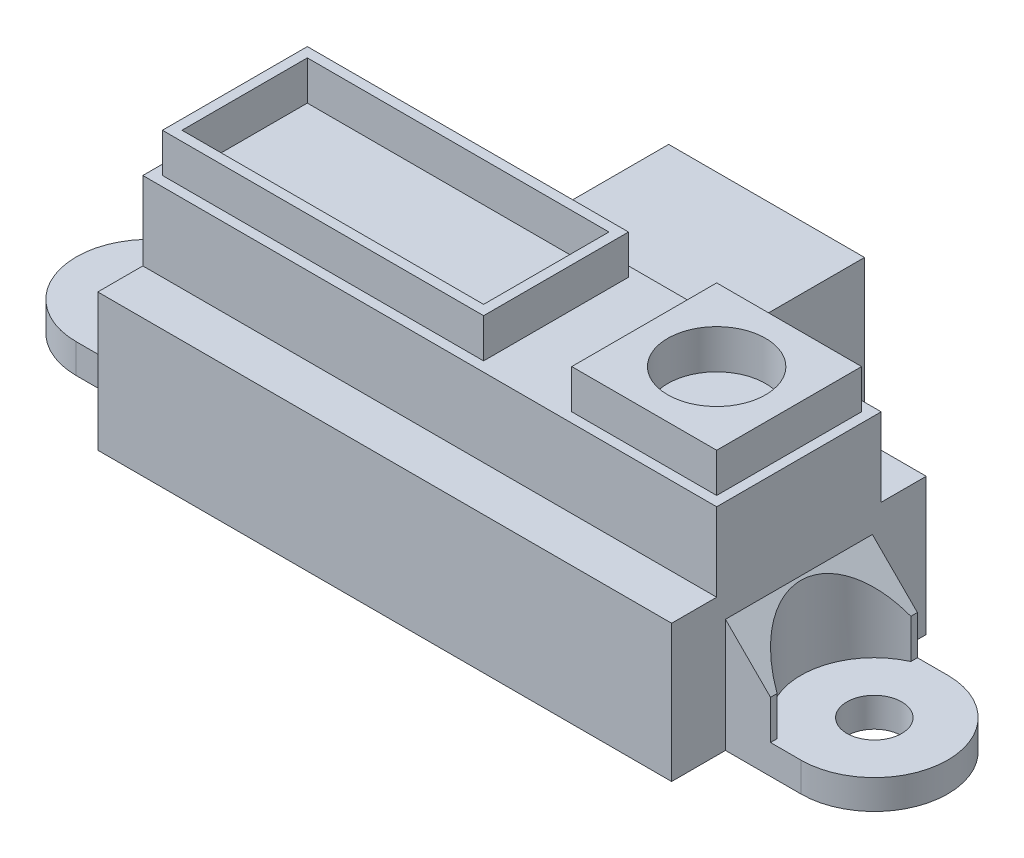
from build123d import *

# Parameters (mm, degrees)
SKETCH_1_W                  = 29.3
SKETCH_1_H                  = 13
EXTRUDE_1_DEPTH             = 7
SKETCH_2_W                  = 29.3
SKETCH_2_H                  = 8.4
EXTRUDE_2_DEPTH             = 4
SKETCH_3_W                  = 16.4
SKETCH_3_H                  = 7.4
SKETCH_3_W_2                = 15.4
SKETCH_3_H_2                = 6.4
SKETCH_3_W_3                = 7.4
SKETCH_3_R                  = 2.5
EXTRUDE_3_DEPTH             = 2
SKETCH_5_R                  = 1.4
EXTRUDE_4_DEPTH             = 5.8
CUT_EXTRUDE_1_DEPTH         = 5
SKETCH_7_R                  = 3.75
CUT_EXTRUDE_2_DEPTH         = 10
SKETCH_8_W                  = 10
SKETCH_8_H                  = 7
EXTRUDE_5_DEPTH             = 6.5
EXTRUDE_5_DIRECTION_2_REACH = 15


with BuildPart() as part:
    # 草图1 → 凸台-拉伸1 (new body)
    with BuildSketch(Plane(origin=(0, 0, 0), x_dir=(1, 0, 0), z_dir=(0, 1, 0))):
        Rectangle(SKETCH_1_W, SKETCH_1_H)
    extrude(amount=EXTRUDE_1_DEPTH)

    # 草图2 → 凸台-拉伸2 (add)
    with BuildSketch(Plane(origin=(0, 7, 0), x_dir=(1, 0, 0), z_dir=(0, 1, 0))):
        Rectangle(SKETCH_2_W, SKETCH_2_H)
    extrude(amount=EXTRUDE_2_DEPTH)

    # 草图3 → 凸台-拉伸3 (add)
    with BuildSketch(Plane(origin=(0, 11, 0), x_dir=(1, 0, 0), z_dir=(0, 1, 0))):
        with Locations((-5.95, 0)):
            Rectangle(SKETCH_3_W, SKETCH_3_H)
        with Locations((-5.95, 0)):
            Rectangle(SKETCH_3_W_2, SKETCH_3_H_2, mode=Mode.SUBTRACT)
        with Locations((10.45, 0)):
            Rectangle(SKETCH_3_W_3, SKETCH_3_H)
        with Locations((10.45, 0)):
            Circle(SKETCH_3_R, mode=Mode.SUBTRACT)
    extrude(amount=EXTRUDE_3_DEPTH)

    # 草图5 → 凸台-拉伸4 (add)
    with BuildSketch(Plane(origin=(0, 0, 0), x_dir=(1, 0, 0), z_dir=(0, 1, 0))):
        with BuildLine():
            Line((-18.5, 3.75), (18.5, 3.75))
            ThreePointArc((18.5, 3.75), (22.25, 0), (18.5, -3.75))
            Line((18.5, -3.75), (-18.5, -3.75))
            ThreePointArc((-18.5, -3.75), (-22.25, 0), (-18.5, 3.75))
        make_face()
        with Locations((18.5, 0)):
            Circle(SKETCH_5_R, mode=Mode.SUBTRACT)
        with Locations((-18.5, 0)):
            Circle(SKETCH_5_R, mode=Mode.SUBTRACT)
    extrude(amount=EXTRUDE_4_DEPTH)

    # 草图6 → 切除-拉伸1 (cut, symmetric)
    with BuildSketch(Plane.XY):
        Polygon((-22.25, 1.5), (-16.95, 1.5), (-16.95, 3.5), (-14.65, 5.8), (-22.25, 5.8), align=None)
        Polygon((22.25, 5.8), (22.25, 1.5), (16.95, 1.5), (16.95, 3.5), (14.65, 5.8), align=None)
    extrude(amount=CUT_EXTRUDE_1_DEPTH, both=True, mode=Mode.SUBTRACT)

    # 草图7 → 切除-拉伸2 (cut)
    with BuildSketch(Plane(origin=(0, 1.5, 0), x_dir=(1, 0, 0), z_dir=(0, 1, 0))):
        with Locations((18.5, 0)):
            Circle(SKETCH_7_R)
        with Locations((-18.5, 0)):
            Circle(SKETCH_7_R)
    extrude(amount=CUT_EXTRUDE_2_DEPTH, mode=Mode.SUBTRACT)

    # 草图8 → 凸台-拉伸5 (add)
    with BuildSketch(Plane(origin=(0, 0, -6.5), x_dir=(-1, 0, 0), z_dir=(0, 0, -1))):
        with Locations((0, 5.1)):
            Rectangle(SKETCH_8_W, SKETCH_8_H)
    extrude(amount=EXTRUDE_5_DEPTH)

    # 草图8 → 凸台-拉伸5 direction 2 (add, up to next)
    with BuildSketch(Plane(origin=(0, 0, -6.5), x_dir=(-1, 0, 0), z_dir=(0, 0, -1)), mode=Mode.PRIVATE) as extrude_5_direction_2_sk1:
        with Locations((0, 5.1)):
            Rectangle(SKETCH_8_W, SKETCH_8_H)
    extrude_5_direction_2_tool1 = extrude(extrude_5_direction_2_sk1.sketch, amount=-EXTRUDE_5_DIRECTION_2_REACH, mode=Mode.PRIVATE) - part.part
    add(extrude_5_direction_2_tool1.solids().sort_by_distance((0, 5.1, -6.5))[0])


solid = part.part
